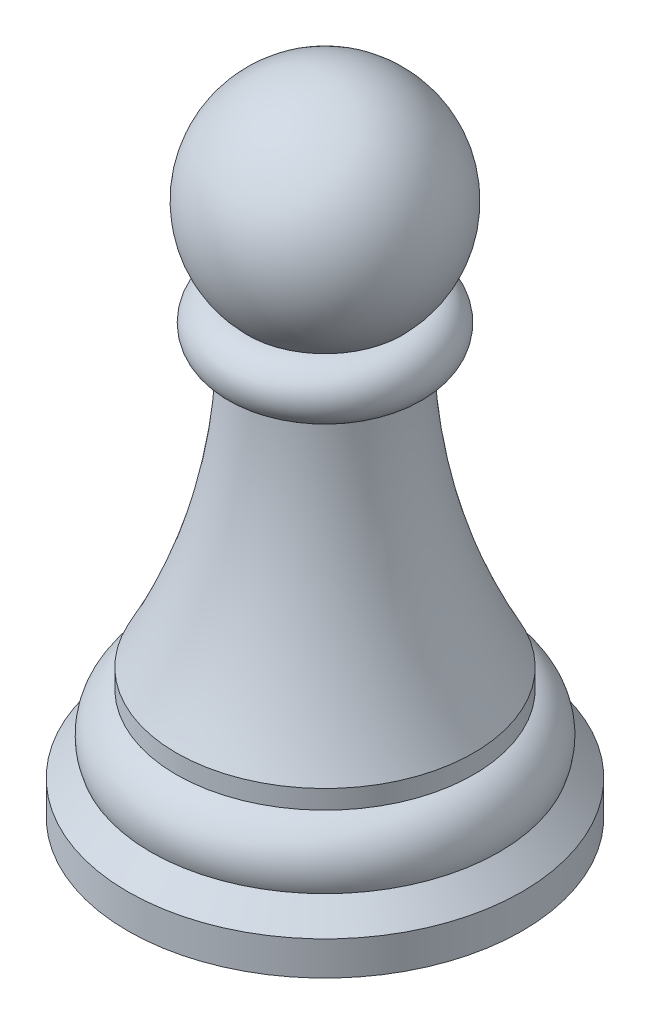
from build123d import *


with BuildPart() as part:
    # Sketch1 → Revolve4 (revolve)
    with BuildSketch(Plane.XY):
        with BuildLine():
            Line((0, 0), (0, 20.718792279))
            ThreePointArc((0, 20.718792279), (3.264480019, 18.531398873), (2.482849316, 14.680350555))
            ThreePointArc((2.482849316, 14.680350555), (3.365856417, 13.797343455), (2.482849316, 12.914336354))
            add(Edge.make_bspline(
                [(2.482849316, 12.914336354), (2.583418025, 8.286863587), (4.787525553, 4.183965741)],
                knots=[0, 0, 0, 1, 1, 1], degree=2))
            Line((4.787525553, 4.183965741), (4.787525553, 3.578409965))
            ThreePointArc((4.787525553, 3.578409965), (5.560964983, 2.876116424), (5.611272713, 1.832615632))
            Line((5.611272713, 1.832615632), (6.35, 1.093888345))
            Line((6.35, 1.093888345), (6.35, 0))
            Line((6.35, 0), (0, 0))
        make_face()
    revolve(axis=Axis((0, 0, 0), (0, 1, 0)))


solid = part.part
